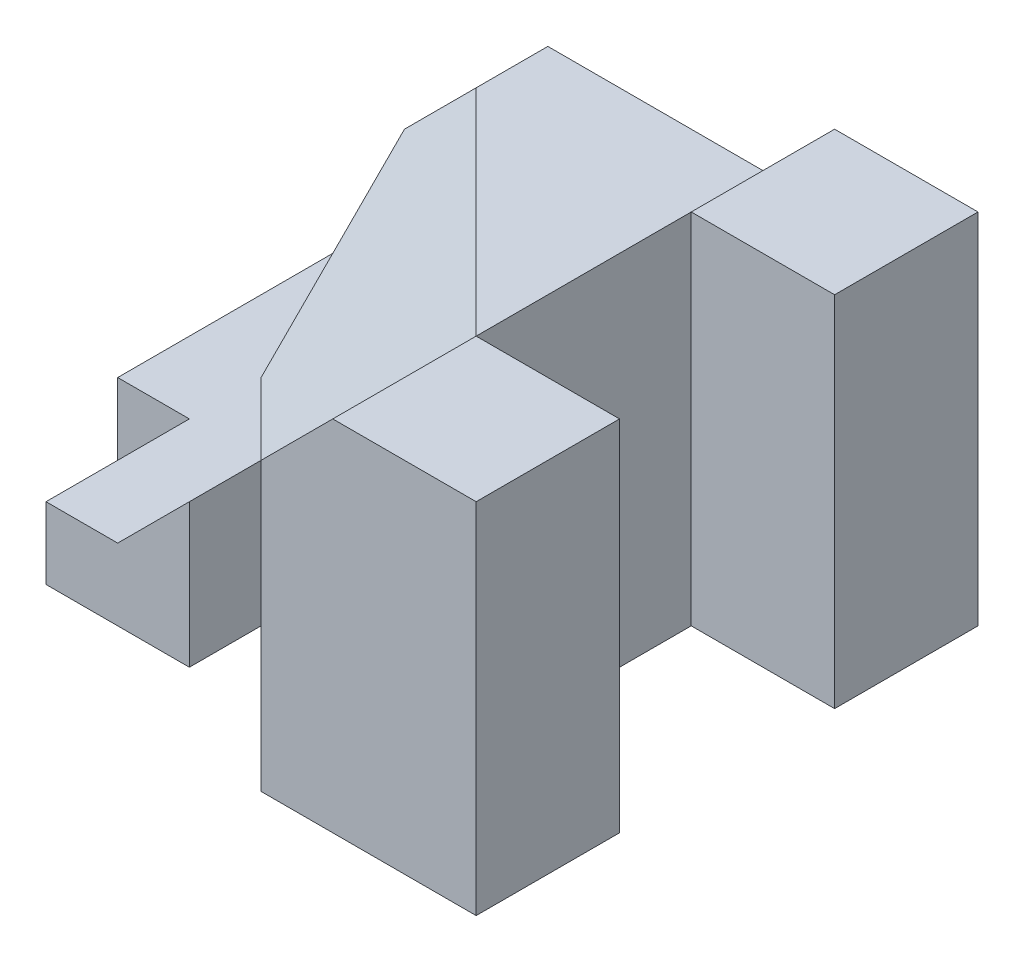
from build123d import *

# Parameters (mm, degrees)
BOSS_EXTRUDE1_DEPTH     = 5
CUT_EXTRUDE1_DEPTH      = 5
CUT_EXTRUDE1_DEPTH_BACK = 2
CUT_EXTRUDE3_DEPTH      = 5
SKETCH5_W               = 4
SKETCH5_H               = 3
CUT_EXTRUDE4_DEPTH      = 1
CUT_EXTRUDE5_DEPTH      = 1
CUT_EXTRUDE6_DEPTH      = 1


with BuildPart() as part:
    # Sketch1 → Boss-Extrude1 (new body)
    with BuildSketch(Plane(origin=(0, 0, 0), x_dir=(1, 0, 0), z_dir=(0, 1, 0))):
        Polygon((0, 0), (0, -2), (-2, -2), (-2, -5), (0, -5), (0, -7), (-3, -7), (-3, -5), (-5, -5), (-5, -6), (-7, -6), (-7, -4), (-8, -4), (-8, 0), align=None)
    extrude(amount=BOSS_EXTRUDE1_DEPTH)

    # Sketch2 → Cut-Extrude1 (cut, two sides)
    with BuildSketch(Plane.XY.offset(6)) as cut_extrude1_sk:
        Polygon((-8, 1), (-6, 1), (-2, 5), (-8, 5), align=None)
    extrude(amount=CUT_EXTRUDE1_DEPTH, mode=Mode.SUBTRACT)
    extrude(cut_extrude1_sk.sketch, amount=-CUT_EXTRUDE1_DEPTH_BACK, mode=Mode.SUBTRACT)

    # Sketch3 → Cut-Extrude3 (cut)
    with BuildSketch(Plane.XY.offset(4)):
        Polygon((-2, 5), (-3, 5), (-8, 5), (-8, 4), (-3, 4), align=None)
    extrude(amount=-CUT_EXTRUDE3_DEPTH, mode=Mode.SUBTRACT)

    # Sketch5 → Cut-Extrude4 (cut)
    with BuildSketch(Plane.ZY.offset(8)):
        with Locations((2, 2.5)):
            Rectangle(SKETCH5_W, SKETCH5_H)
    extrude(amount=-CUT_EXTRUDE4_DEPTH, mode=Mode.SUBTRACT)

    # Sketch7 → Cut-Extrude5 (cut)
    with BuildSketch(Plane(origin=(0, 0, 0), x_dir=(-1, 0, 0), z_dir=(0, 0, -1))):
        Polygon((6, 4), (7, 3), (7, 4), align=None)
    extrude(amount=-CUT_EXTRUDE5_DEPTH, mode=Mode.SUBTRACT)

    # 3DSketch1 → Cut-Extrude6 (cut, along a direction that is not the sketch's normal)
    with BuildSketch(Plane(origin=(-7, 1, 3), x_dir=(0.7844645405527364, 0.588348405414552, 0.19611613513818382), z_dir=(-0.5773502691896255, 0.577350269189626, 0.5773502691896261))):
        Polygon((0, 0), (0.784464541, 2.717464882), (2.157277487, 3.057147992), (5.099019514, 0), (0.980580676, -1.019049331), align=None)
    extrude(amount=CUT_EXTRUDE6_DEPTH, dir=(-1, 0, 0), mode=Mode.SUBTRACT)


with BuildPart() as body_2:
    # of the pieces the cut leaves, the one that is kept (cut_extrude6_keep)
    add(part.part.solids().sort_by_distance((0, 0, 0))[0])


solid = body_2.part
